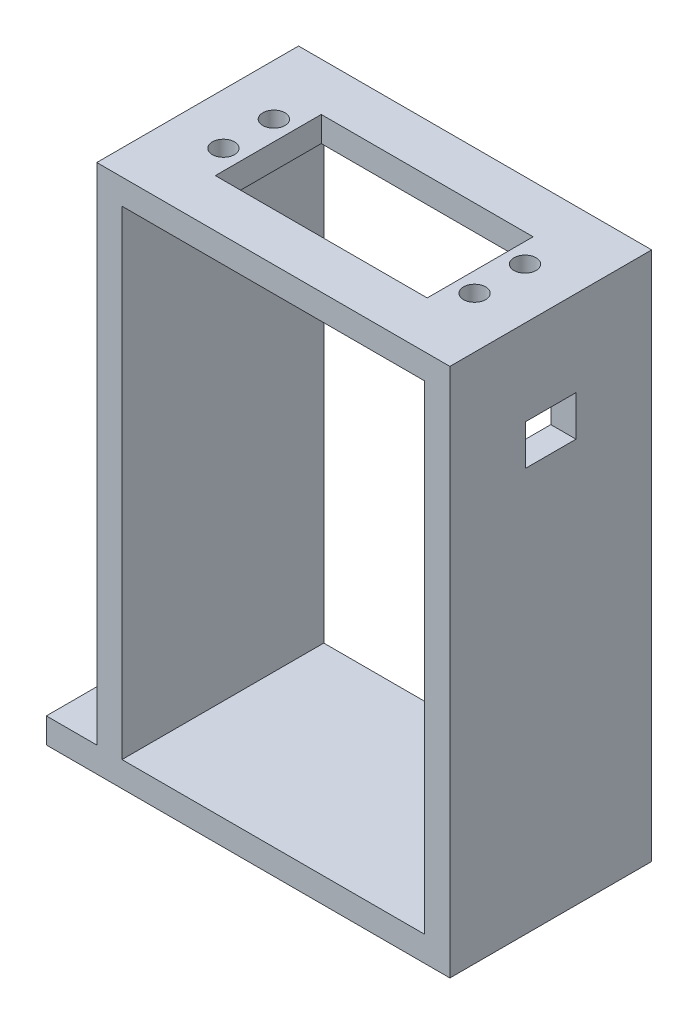
from build123d import *

# Parameters (mm, degrees)
SKETCH2_W           = 80
SKETCH2_H           = 40
SKETCH2_R           = 2.2
BOSS_EXTRUDE1_DEPTH = 5
SKETCH3_W           = 5
SKETCH3_H           = 40
BOSS_EXTRUDE2_DEPTH = 100
SKETCH4_W           = 10
SKETCH4_H           = 8
CUT_EXTRUDE1_DEPTH  = 10
SKETCH5_W           = 40
SKETCH5_H           = 5
BOSS_EXTRUDE3_DEPTH = 70
SKETCH6_R           = 2.2
SKETCH6_W           = 42
SKETCH6_H           = 21
CUT_EXTRUDE2_DEPTH  = 70
SKETCH7_R           = 4
SKETCH7_R_2         = 2.2
CUT_EXTRUDE3_DEPTH  = 3


with BuildPart() as part:
    # Sketch2 → Boss-Extrude1 (new body)
    with BuildSketch(Plane(origin=(0, 0, 0), x_dir=(1, 0, 0), z_dir=(0, 1, 0))):
        with Locations((-40, 20)):
            Rectangle(SKETCH2_W, SKETCH2_H)
        with Locations((-75, 25)):
            Circle(SKETCH2_R, mode=Mode.SUBTRACT)
        with Locations((-75, 15)):
            Circle(SKETCH2_R, mode=Mode.SUBTRACT)
    extrude(amount=BOSS_EXTRUDE1_DEPTH)

    # Sketch3 → Boss-Extrude2 (add)
    with BuildSketch(Plane(origin=(0, 5, 0), x_dir=(1, 0, 0), z_dir=(0, 1, 0))):
        with Locations((-2.5, 20)):
            Rectangle(SKETCH3_W, SKETCH3_H)
        with Locations((-67.5, 20)):
            Rectangle(SKETCH3_W, SKETCH3_H)
    extrude(amount=BOSS_EXTRUDE2_DEPTH)

    # Sketch4 → Cut-Extrude1 (cut)
    with BuildSketch(Plane(origin=(0, 0, 0), x_dir=(0, 0, -1), z_dir=(1, 0, 0))):
        with Locations((20, 84)):
            Rectangle(SKETCH4_W, SKETCH4_H)
    extrude(amount=-CUT_EXTRUDE1_DEPTH, mode=Mode.SUBTRACT)

    # Sketch5 → Boss-Extrude3 (add)
    with BuildSketch(Plane(origin=(0, 0, 0), x_dir=(0, 0, -1), z_dir=(1, 0, 0))):
        with Locations((20, 102.5)):
            Rectangle(SKETCH5_W, SKETCH5_H)
    extrude(amount=-BOSS_EXTRUDE3_DEPTH)

    # Sketch6 → Cut-Extrude2 (cut)
    with BuildSketch(Plane(origin=(0, 105, 0), x_dir=(1, 0, 0), z_dir=(0, 1, 0))):
        with Locations((-59.89, 25)):
            Circle(SKETCH6_R)
        with Locations((-59.89, 15)):
            Circle(SKETCH6_R)
        with Locations((-10.11, 15)):
            Circle(SKETCH6_R)
        with Locations((-10.11, 25)):
            Circle(SKETCH6_R)
        with Locations((-35, 20)):
            Rectangle(SKETCH6_W, SKETCH6_H)
    extrude(amount=-CUT_EXTRUDE2_DEPTH, mode=Mode.SUBTRACT)

    # Sketch7 → Cut-Extrude3 (cut)
    with BuildSketch(Plane.XZ):
        with Locations((-75, -15)):
            Circle(SKETCH7_R)
        with Locations((-75, -15)):
            Circle(SKETCH7_R_2, mode=Mode.SUBTRACT)
        with Locations((-75, -25)):
            Circle(SKETCH7_R)
        with Locations((-75, -25)):
            Circle(SKETCH7_R_2, mode=Mode.SUBTRACT)
    extrude(amount=-CUT_EXTRUDE3_DEPTH, mode=Mode.SUBTRACT)


solid = part.part
